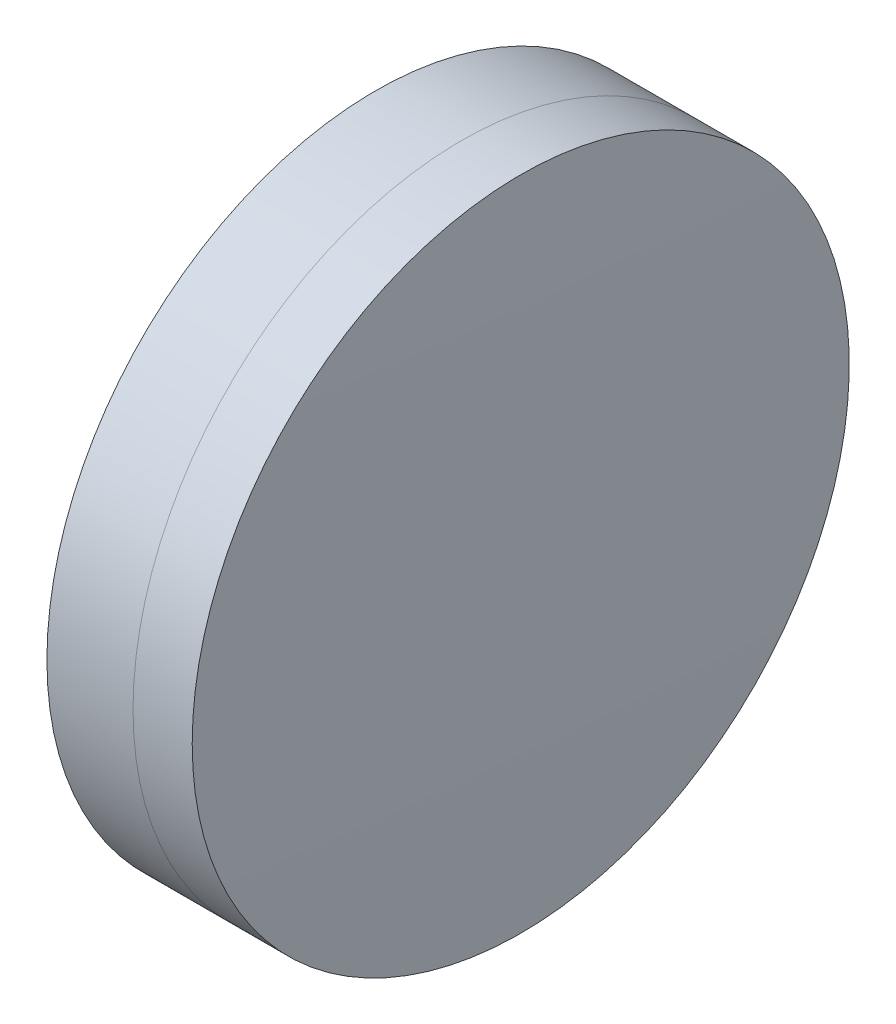
from build123d import *


with BuildPart() as part:
    # 草图1 one side → 旋转1 (revolve)
    with BuildSketch(Plane(origin=(0, 0, 0), x_dir=(1, 0, 0), z_dir=(0, 1, 0)), mode=Mode.PRIVATE) as revolve_1_sk:
        with BuildLine():
            ThreePointArc((363.938622172, 12.7), (363.759246501, 6.351125973), (363.699447543, 0))
            Line((363.699447543, 0), (367.699447543, 0))
            ThreePointArc((367.699447543, 0), (367.59136166, 6.353676353), (367.267229093, 12.7))
            Line((367.267229093, 12.7), (363.938622172, 12.7))
        make_face()
    revolve(revolve_1_sk.sketch.rotate(Axis((235.807450691, 0, 0), (1, 0, 0)), 180), axis=Axis((235.807450691, 0, 0), (1, 0, 0)))  # turned: the seam where the file's is


with BuildPart() as body_2:
    # 草图2 one side → 旋转3 (revolve)
    with BuildSketch(Plane(origin=(0, 0, 0), x_dir=(1, 0, 0), z_dir=(0, 1, 0)), mode=Mode.PRIVATE) as revolve_3_sk:
        with BuildLine():
            Line((369.554748101, 12.7), (367.267229093, 12.7))
            ThreePointArc((367.267229093, 12.7), (367.59136166, 6.353676353), (367.699447543, 0))
            Line((367.699447543, 0), (369.699447543, 0))
            ThreePointArc((369.699447543, 0), (369.663271509, 6.350412151), (369.554748101, 12.7))
        make_face()
    revolve(revolve_3_sk.sketch.rotate(Axis((-0.551919993, 0, 0), (1, 0, 0)), 180), axis=Axis((-0.551919993, 0, 0), (1, 0, 0)))  # turned: the seam where the file's is


solid = Compound([part.part, body_2.part])
